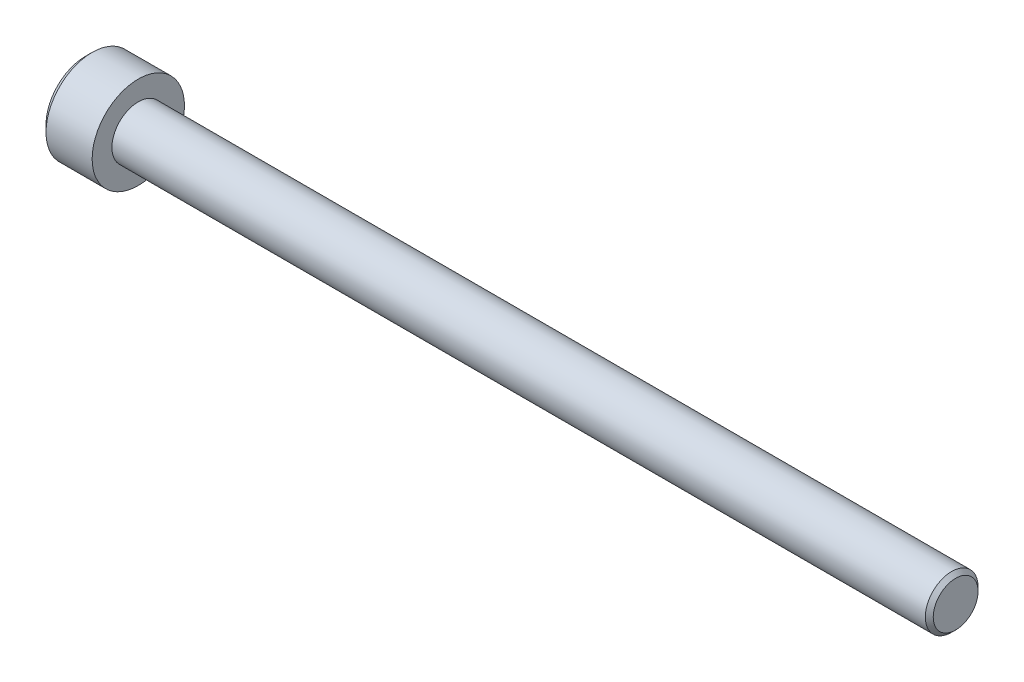
from build123d import *

# Parameters (mm, degrees)
CHAMFER1_SIZE      = 0.3
CUT_EXTRUDE1_DEPTH = 1
CHAMFER2_SIZE      = 0.5


with BuildPart() as part:
    # Sketch1 → Revolve1 (revolve)
    with BuildSketch(Plane.XY):
        Polygon((0, 0), (66, 0), (66, 2), (4, 2), (4, 3.5), (0, 3.5), align=None)
    revolve(axis=Axis((0, 0, 0), (1, 0, 0)))

    # Chamfer1
    chamfer1_edges = [part.edges().sort_by_distance(p)[0] for p in [
        (66, -2, 0),
    ]]
    chamfer(chamfer1_edges, length=CHAMFER1_SIZE)

    # Sketch2 → Cut-Extrude1 (cut)
    with BuildSketch(Plane.ZY):
        Polygon((0, 2), (-1.732050808, 1), (-1.732050808, -1), (0, -2), (1.732050808, -1), (1.732050808, 1), align=None)
    extrude(amount=-CUT_EXTRUDE1_DEPTH, mode=Mode.SUBTRACT)

    # Chamfer2
    chamfer2_edges = [part.edges().sort_by_distance(p)[0] for p in [
        (0, -3.5, 0),
    ]]
    chamfer(chamfer2_edges, length=CHAMFER2_SIZE)


solid = part.part
